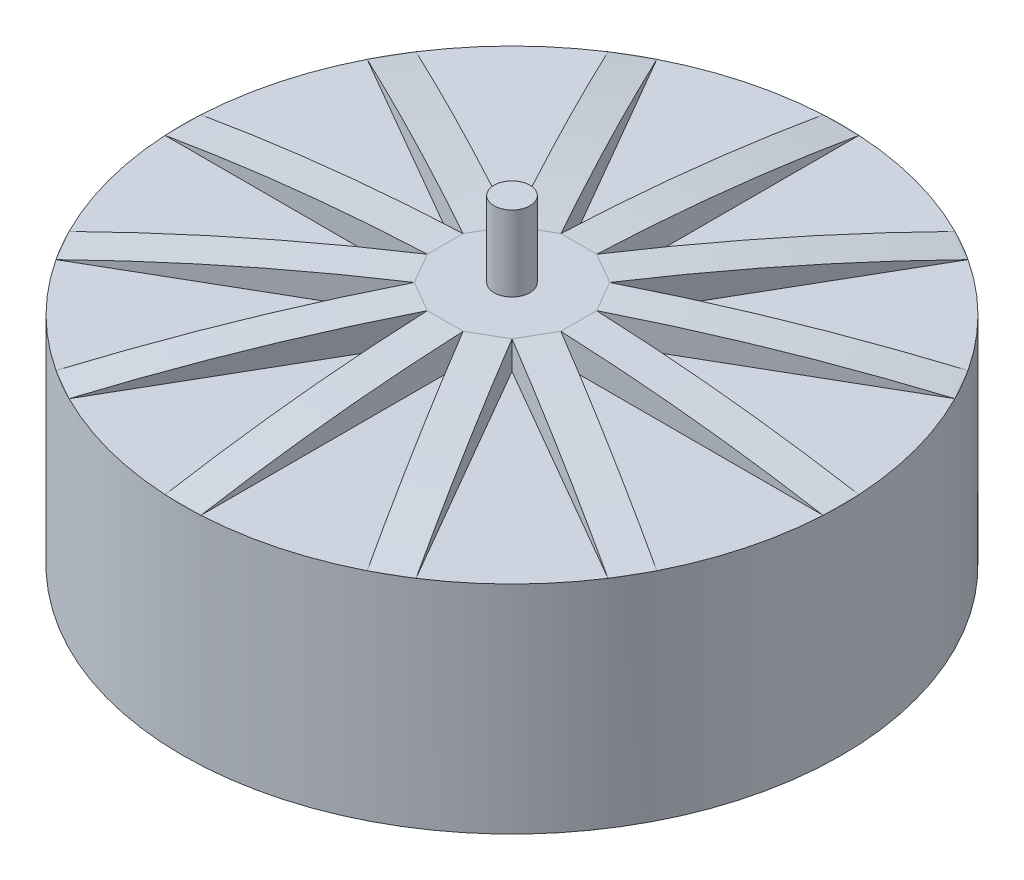
from build123d import *

# Parameters (mm, degrees)
SKETCH_1_R               = 35
EXTRUDE_1_DEPTH          = 23
SKETCH_2_R               = 1.9
EXTRUDE_2_DEPTH          = 11
SKETCH_4_W               = 3.8
SKETCH_4_H               = 34.948390521
EXTRUDE_6_DEPTH          = 3
PATTERN_CIRCULAR_1_COUNT = 12
CUT_EXTRUDE_3_DEPTH      = 4
PATTERN_CIRCULAR_2_COUNT = 12


with BuildPart() as part:
    # Эскиз1 → Бобышка-Вытянуть1 (new body)
    with BuildSketch(Plane(origin=(0, 0, 0), x_dir=(1, 0, 0), z_dir=(0, 1, 0))):
        Circle(SKETCH_1_R)
    extrude(amount=EXTRUDE_1_DEPTH)

    # Эскиз2 → Бобышка-Вытянуть2 (add)
    with BuildSketch(Plane(origin=(0, 23, 0), x_dir=(1, 0, 0), z_dir=(0, 1, 0))):
        Circle(SKETCH_2_R)
    extrude(amount=EXTRUDE_2_DEPTH)

    # Эскиз4 → Бобышка-Вытянуть6 (add)
    with BuildSketch(Plane(origin=(0, 23, 0), x_dir=(1, 0, 0), z_dir=(0, 1, 0))):
        with Locations((0, 17.474195261)):
            Rectangle(SKETCH_4_W, SKETCH_4_H)
    extrude_6 = extrude(amount=EXTRUDE_6_DEPTH)

    # Круговой массив1: Бобышка-Вытянуть6 ×12 about axis
    pattern_circular_1_axis = Axis((0, 0, 0), (0, 1, 0))
    for i in range(1, PATTERN_CIRCULAR_1_COUNT):
        add(extrude_6.rotate(pattern_circular_1_axis, i * 360 / PATTERN_CIRCULAR_1_COUNT))

    # Эскиз12 → Вырез-Вытянуть3 (cut)
    with BuildSketch(Plane(origin=(-0.95, 0, 1.645448267), x_dir=(0.866025404, 0, 0.5), z_dir=(-0.5, 0, 0.866025404))):
        with BuildLine():
            add(Edge.make_bspline(
                [(-34.948390521, 23), (-21.115111168, 25.388771588), (-7.090896534, 26)],
                knots=[0, 0, 0, 1, 1, 1], degree=2))
            Line((-7.090896534, 26), (-34.948390521, 26))
            Line((-34.948390521, 26), (-34.948390521, 23))
        make_face()
    cut_extrude_3 = extrude(amount=-CUT_EXTRUDE_3_DEPTH, mode=Mode.SUBTRACT)

    # Круговой массив2: Вырез-Вытянуть3 ×12 about axis
    pattern_circular_2_axis = Axis((0, 0, 0), (0, -1, 0))
    for i in range(1, PATTERN_CIRCULAR_2_COUNT):
        add(cut_extrude_3.rotate(pattern_circular_2_axis, i * 360 / PATTERN_CIRCULAR_2_COUNT), mode=Mode.SUBTRACT)


solid = part.part
